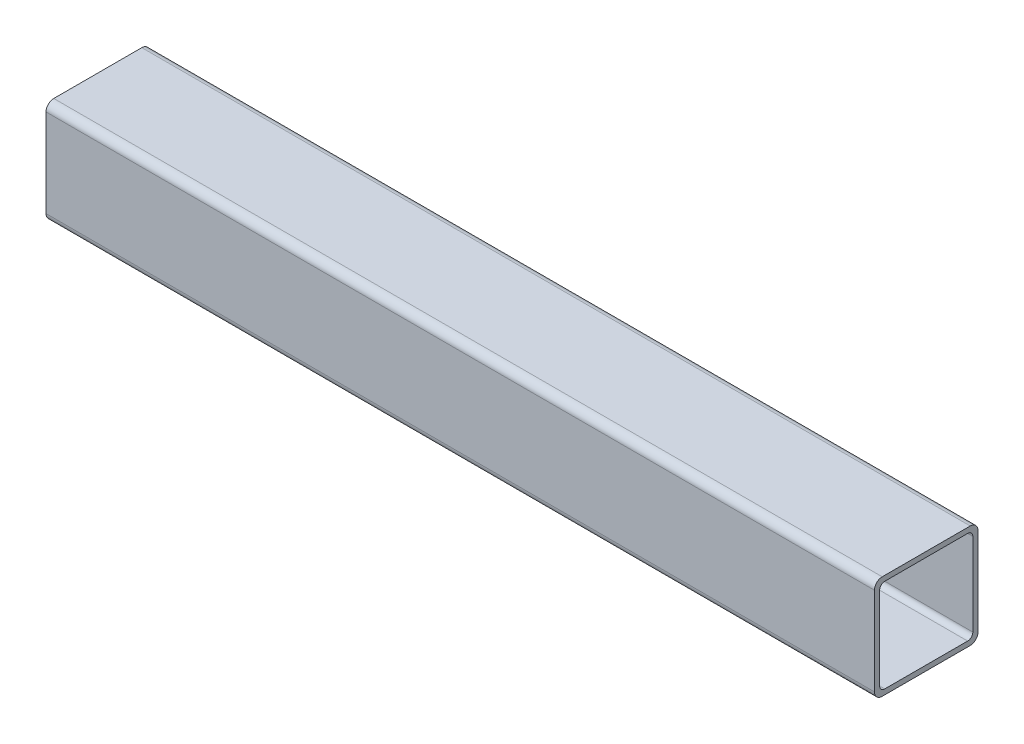
from build123d import *

# Parameters (mm, degrees)
EXTRUDE_1_DEPTH = 320


with BuildPart() as part:
    # Эскиз1 → Бобышка-Вытянуть1 (new body)
    with BuildSketch(Plane(origin=(0, 0, 0), x_dir=(0, 0, -1), z_dir=(1, 0, 0))):
        with BuildLine():
            Line((-17, 20), (17, 20))
            ThreePointArc((17, 20), (19.121320344, 19.121320344), (20, 17))
            Line((20, 17), (20, -17))
            ThreePointArc((20, -17), (19.121320344, -19.121320344), (17, -20))
            Line((17, -20), (-17, -20))
            ThreePointArc((-17, -20), (-19.121320344, -19.121320344), (-20, -17))
            Line((-20, -17), (-20, 17))
            ThreePointArc((-20, 17), (-19.121320344, 19.121320344), (-17, 20))
        make_face()
        with BuildLine():
            Line((-16, 18), (16, 18))
            ThreePointArc((16, 18), (17.414213562, 17.414213562), (18, 16))
            Line((18, 16), (18, -16))
            ThreePointArc((18, -16), (17.414213562, -17.414213562), (16, -18))
            Line((16, -18), (-16, -18))
            ThreePointArc((-16, -18), (-17.414213562, -17.414213562), (-18, -16))
            Line((-18, -16), (-18, 16))
            ThreePointArc((-18, 16), (-17.414213562, 17.414213562), (-16, 18))
        make_face(mode=Mode.SUBTRACT)
    extrude(amount=-EXTRUDE_1_DEPTH)


solid = part.part
